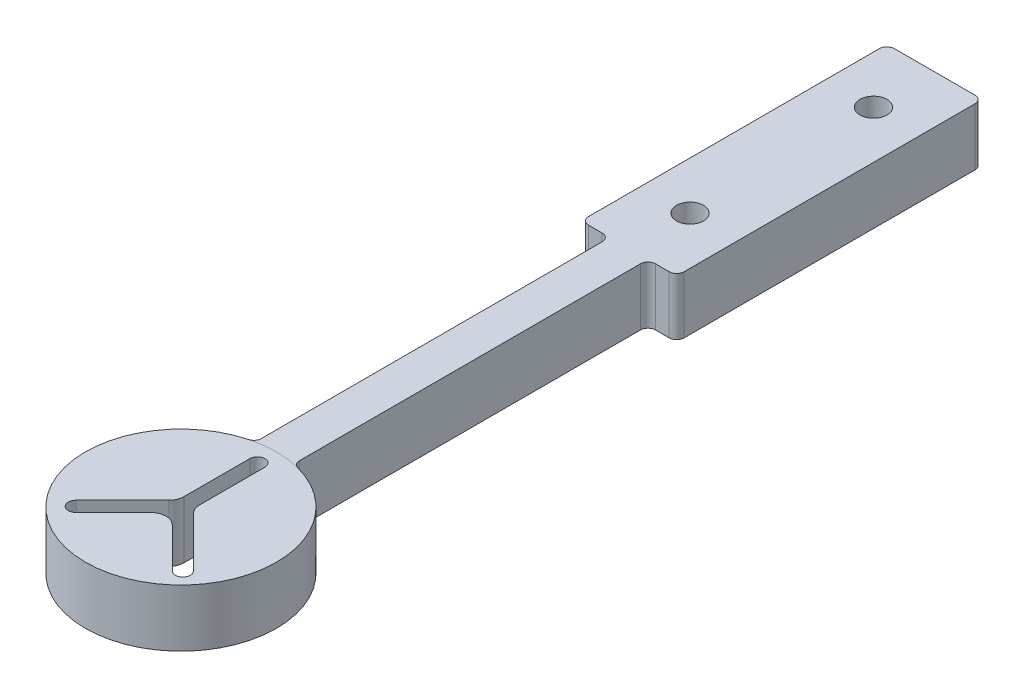
from build123d import *

# Parameters (mm, degrees)
BOSS_EXTRUDE1_DEPTH = 9.525
SKETCH2_R           = 2.2479
CUT_EXTRUDE1_DEPTH  = 93.175319142
CUT_EXTRUDE2_DEPTH  = 93.175319142
FILLET1_R           = 1.25
FILLET2_R           = 2.54


with BuildPart() as part:
    # Sketch1 → Boss-Extrude1 (new body)
    with BuildSketch(Plane(origin=(0, 0, 0), x_dir=(1, 0, 0), z_dir=(0, 1, 0))):
        with BuildLine():
            Line((-7.9375, 50.8), (7.9375, 50.8))
            Line((7.9375, 50.8), (7.9375, 0))
            Line((7.9375, 0), (3.175, 0))
            Line((3.175, 0), (3.175, -58.867740133))
            ThreePointArc((3.175, -58.867740133), (0, -90.297), (-3.175, -58.867740133))
            Line((-3.175, -58.867740133), (-3.175, 0))
            Line((-3.175, 0), (-7.9375, 0))
            Line((-7.9375, 0), (-7.9375, 50.8))
        make_face()
    extrude(amount=BOSS_EXTRUDE1_DEPTH)

    # Sketch2 → Cut-Extrude1 (cut, through all)
    with BuildSketch(Plane(origin=(0, 9.525, 0), x_dir=(1, 0, 0), z_dir=(0, 1, 0))):
        with Locations((0, 40.64)):
            Circle(SKETCH2_R)
        with Locations((0, 10.16)):
            Circle(SKETCH2_R)
    extrude(amount=-CUT_EXTRUDE1_DEPTH, mode=Mode.SUBTRACT)

    # Sketch3 → Cut-Extrude2 (cut, through all)
    with BuildSketch(Plane(origin=(0, 9.525, 0), x_dir=(1, 0, 0), z_dir=(0, 1, 0))):
        with BuildLine():
            Line((0.059974982, -75.919115272), (8.472150299, -84.331290589))
            ThreePointArc((8.472150299, -84.331290589), (10.232280498, -84.331290589), (10.232280498, -82.571160389))
            Line((10.232280498, -82.571160389), (1.2446, -73.583479891))
            Line((1.2446, -73.583479891), (1.2446, -61.722))
            ThreePointArc((1.2446, -61.722), (0, -60.4774), (-1.2446, -61.722))
            Line((-1.2446, -61.722), (-1.2446, -73.703429855))
            Line((-1.2446, -73.703429855), (-9.716750299, -82.175580154))
            ThreePointArc((-9.716750299, -82.175580154), (-9.716750299, -83.935710353), (-7.956620099, -83.935710353))
            Line((-7.956620099, -83.935710353), (0.059974982, -75.919115272))
        make_face()
    extrude(amount=-CUT_EXTRUDE2_DEPTH, mode=Mode.SUBTRACT)

    # Fillet1
    fillet1_edges = [part.edges().sort_by_distance(p)[0] for p in [
        (7.9375, 4.7625, -50.8),
        (-7.9375, 4.7625, -50.8),
        (-7.9375, 4.7625, 0),
        (-3.175, 4.7625, 0),
        (7.9375, 4.7625, 0),
        (3.175, 4.7625, 0),
        (3.175, 4.7625, 58.867740133),
        (-3.175, 4.7625, 58.867740133),
    ]]
    fillet(fillet1_edges, radius=FILLET1_R)

    # Fillet2
    fillet2_edges = [part.edges().sort_by_distance(p)[0] for p in [
        (0.059974982, 4.7625, 75.919115272),
        (1.2446, 4.7625, 73.583479891),
        (-1.2446, 4.7625, 73.703429855),
    ]]
    fillet(fillet2_edges, radius=FILLET2_R)


solid = part.part
